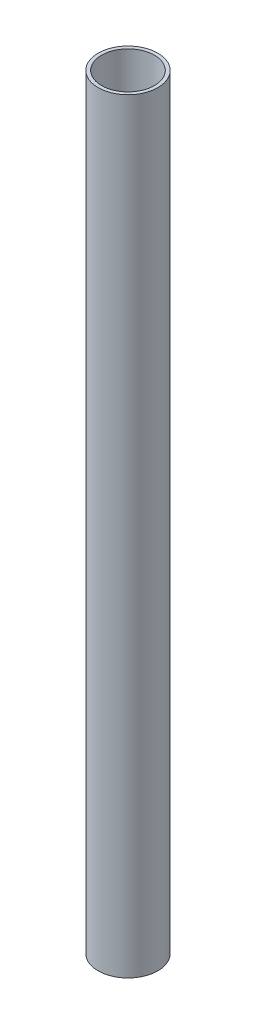
from build123d import *

# Parameters (mm, degrees)
SKETCH_1_R      = 13
SKETCH_1_R_2    = 11.5
EXTRUDE_1_DEPTH = 333


with BuildPart() as part:
    # 草图1 → 凸台-拉伸1 (new body)
    with BuildSketch(Plane(origin=(0, 0, 0), x_dir=(1, 0, 0), z_dir=(0, 1, 0))):
        Circle(SKETCH_1_R)
        Circle(SKETCH_1_R_2, mode=Mode.SUBTRACT)
    extrude(amount=EXTRUDE_1_DEPTH)


solid = part.part
